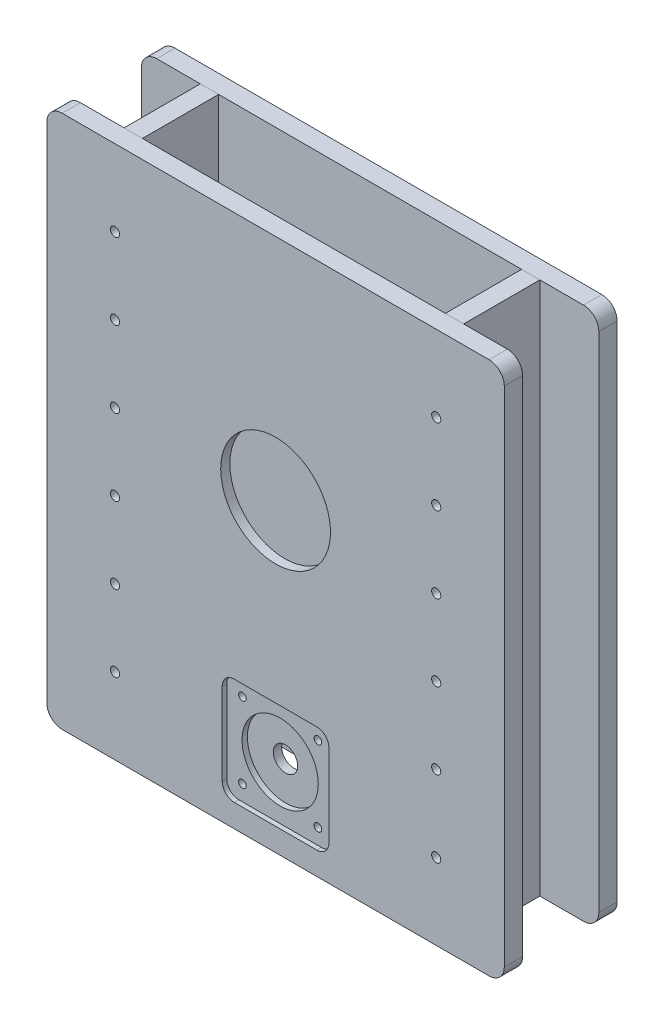
from build123d import *

# Parameters (mm, degrees)
SKETCH1_W               = 300
SKETCH1_H               = 300
BOSS_EXTRUDE1_DEPTH     = 12
SKETCH2_R               = 45
CUT_EXTRUDE1_DEPTH      = 6
SKETCH3_R               = 36
CUT_EXTRUDE2_DEPTH      = 6
SKETCH4_W               = 300
SKETCH4_H               = 50
BOSS_EXTRUDE2_DEPTH     = 12
SKETCH6_R               = 8
SKETCH6_R_2             = 2.5
CUT_EXTRUDE3_DEPTH      = 12
SKETCH6_3_R             = 25
CUT_EXTRUDE4_DEPTH      = 6.5
SKETCH6_4_W             = 70
SKETCH6_4_H             = 70
CUT_EXTRUDE5_DEPTH      = 3
FILLET1_R               = 8
CUT_EXTRUDE6_DEPTH      = 251.287834303
CUT_EXTRUDE6_DEPTH_BACK = 251.287834303
SKETCH7_R               = 3
SKETCH8_W               = 12
SKETCH8_H               = 350
SKETCH8_R               = 3
BOSS_EXTRUDE3_DEPTH     = 50
BOSS_EXTRUDE3_2_DEPTH   = 50
SKETCH9_W               = 300
SKETCH9_H               = 350
BOSS_EXTRUDE4_DEPTH     = 12
FILLET2_R               = 10
FILLET3_R               = 10


with BuildPart() as part:
    # Sketch1 → Boss-Extrude1 (new body)
    with BuildSketch(Plane(origin=(0, 0, 0), x_dir=(0, 1, 0), z_dir=(0, 0, 1))):
        Rectangle(SKETCH1_W, SKETCH1_H)
    extrude(amount=BOSS_EXTRUDE1_DEPTH)

    # Sketch2 → Cut-Extrude1 (cut)
    with BuildSketch(Plane(origin=(0, 0, 0), x_dir=(-1, 0, 0), z_dir=(0, 0, -1))):
        Circle(SKETCH2_R)
    extrude(amount=-CUT_EXTRUDE1_DEPTH, mode=Mode.SUBTRACT)

    # Sketch3 → Cut-Extrude2 (cut)
    with BuildSketch(Plane(origin=(0, 0, 6), x_dir=(1, 0, 0), z_dir=(0, 0, -1))):
        Circle(SKETCH3_R)
    extrude(amount=-CUT_EXTRUDE2_DEPTH, mode=Mode.SUBTRACT)

    # Sketch4 → Boss-Extrude2 (add)
    with BuildSketch(Plane.XY.offset(12)):
        with Locations((0, -175)):
            Rectangle(SKETCH4_W, SKETCH4_H)
    extrude(amount=-BOSS_EXTRUDE2_DEPTH)

    # Sketch6 → Cut-Extrude3 (cut)
    with BuildSketch(Plane.XY.offset(12)):
        with Locations((0, -150)):
            Circle(SKETCH6_R)
        with Locations((-24.748737342, -125.251262658)):
            Circle(SKETCH6_R_2)
        with Locations((24.748737342, -125.251262658)):
            Circle(SKETCH6_R_2)
        with Locations((24.748737342, -174.748737342)):
            Circle(SKETCH6_R_2)
        with Locations((-24.748737342, -174.748737342)):
            Circle(SKETCH6_R_2)
    extrude(amount=-CUT_EXTRUDE3_DEPTH, mode=Mode.SUBTRACT)

    # Sketch6_3 → Cut-Extrude4 (cut)
    with BuildSketch(Plane.XY.offset(12)):
        with Locations((0, -150)):
            Circle(SKETCH6_3_R)
    extrude(amount=-CUT_EXTRUDE4_DEPTH, mode=Mode.SUBTRACT)

    # Sketch6_4 → Cut-Extrude5 (cut)
    with BuildSketch(Plane.XY.offset(12)):
        with Locations((0, -150)):
            Rectangle(SKETCH6_4_W, SKETCH6_4_H)
    extrude(amount=-CUT_EXTRUDE5_DEPTH, mode=Mode.SUBTRACT)

    # Fillet1
    fillet1_edges = [part.edges().sort_by_distance(p)[0] for p in [
        (35, -185, 10.5),
        (-35, -185, 10.5),
        (-35, -115, 10.5),
        (35, -115, 10.5),
    ]]
    fillet(fillet1_edges, radius=FILLET1_R)

    # Sketch7 → Cut-Extrude6 (cut, two sides: drawn at the far end of the back side and taken through both)
    with BuildSketch(Plane.XY.offset(12).offset(-CUT_EXTRUDE6_DEPTH_BACK)):
        with Locations((-105.352654621, 0)):
            Circle(SKETCH7_R)
        with Locations((-105.352654621, -50)):
            Circle(SKETCH7_R)
        with Locations((-105.352654621, -100)):
            Circle(SKETCH7_R)
        with Locations((-105.352654621, -150)):
            Circle(SKETCH7_R)
        with Locations((-105.352654621, 50)):
            Circle(SKETCH7_R)
        with Locations((-105.352654621, 100)):
            Circle(SKETCH7_R)
        with Locations((105.352654621, -150)):
            Circle(SKETCH7_R)
        with Locations((105.352654621, -100)):
            Circle(SKETCH7_R)
        with Locations((105.352654621, -50)):
            Circle(SKETCH7_R)
        with Locations((105.352654621, 0)):
            Circle(SKETCH7_R)
        with Locations((105.352654621, 50)):
            Circle(SKETCH7_R)
        with Locations((105.352654621, 100)):
            Circle(SKETCH7_R)
    extrude(amount=CUT_EXTRUDE6_DEPTH + CUT_EXTRUDE6_DEPTH_BACK, mode=Mode.SUBTRACT)

    # Fillet2
    fillet2_edges = [part.edges().sort_by_distance(p)[0] for p in [
        (150, 150, 6),
        (150, -200, 6),
        (-150, 150, 6),
        (-150, -200, 6),
    ]]
    fillet(fillet2_edges, radius=FILLET2_R)


with BuildPart() as body_2:
    # Sketch8 → Boss-Extrude3 (new body)
    with BuildSketch(Plane(origin=(0, 0, 0), x_dir=(1, 0, 0), z_dir=(0, 0, -1))):
        with Locations((-105.352654621, 25)):
            Rectangle(SKETCH8_W, SKETCH8_H)
        with Locations((-105.352654621, -100)):
            Circle(SKETCH8_R, mode=Mode.SUBTRACT)
    extrude(amount=BOSS_EXTRUDE3_DEPTH)


with BuildPart() as body_3:
    # Sketch8 → Boss-Extrude3 2 (new body)
    with BuildSketch(Plane(origin=(0, 0, 0), x_dir=(1, 0, 0), z_dir=(0, 0, -1))):
        with Locations((105.352654621, 25)):
            Rectangle(SKETCH8_W, SKETCH8_H)
    extrude(amount=BOSS_EXTRUDE3_2_DEPTH)


with BuildPart() as body_4:
    # Sketch9 → Boss-Extrude4 (new body)
    with BuildSketch(Plane(origin=(0, 0, -50), x_dir=(1, 0, 0), z_dir=(0, 0, -1))):
        with Locations((0, 25)):
            Rectangle(SKETCH9_W, SKETCH9_H)
    extrude(amount=BOSS_EXTRUDE4_DEPTH)

    # Fillet3
    fillet3_edges = [body_4.edges().sort_by_distance(p)[0] for p in [
        (-150, -200, -56),
        (150, -200, -56),
        (-150, 150, -56),
        (150, 150, -56),
    ]]
    fillet(fillet3_edges, radius=FILLET3_R)


solid = Compound([part.part, body_2.part, body_3.part, body_4.part])
